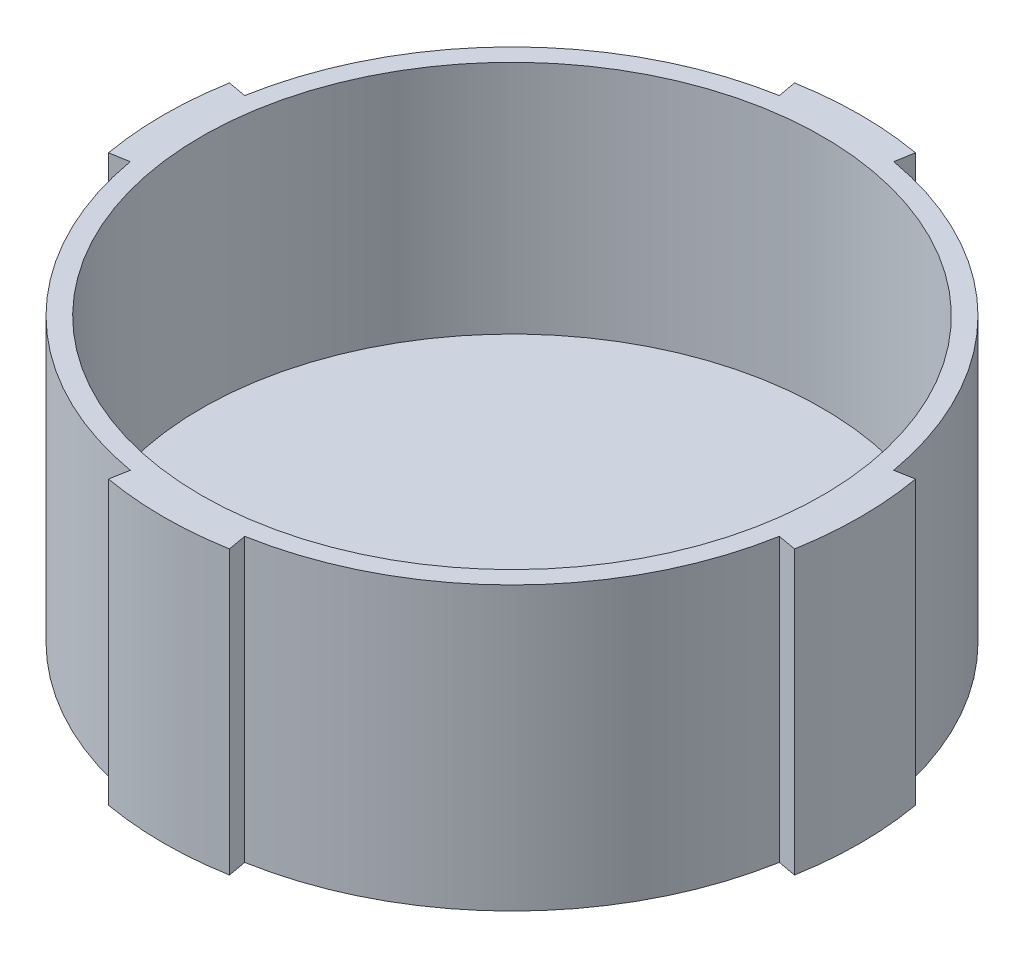
from build123d import *

# Parameters (mm, degrees)
SKETCH1_R           = 37
BOSS_EXTRUDE1_DEPTH = 30
CUT_EXTRUDE1_DEPTH  = 30
SKETCH3_R           = 33
CUT_EXTRUDE2_DEPTH  = 25


with BuildPart() as part:
    # Sketch1 → Boss-Extrude1 (new body)
    with BuildSketch(Plane(origin=(0, 0, 0), x_dir=(1, 0, 0), z_dir=(0, 1, 0))):
        Circle(SKETCH1_R)
    extrude(amount=BOSS_EXTRUDE1_DEPTH)

    # Sketch2 → Cut-Extrude1 (cut)
    with BuildSketch(Plane(origin=(0, 30, 0), x_dir=(1, 0, 0), z_dir=(0, 1, 0))):
        with BuildLine():
            Line((6.424982574, 36.437886861), (6.077686218, 34.468271355))
            ThreePointArc((6.077686218, 34.468271355), (24.748737342, 24.748737342), (34.468271355, 6.077686218))
            Line((34.468271355, 6.077686218), (36.437886861, 6.424982574))
            ThreePointArc((36.437886861, 6.424982574), (26.162950904, 26.162950904), (6.424982574, 36.437886861))
        make_face()
        with BuildLine():
            Line((36.437886861, -6.424982574), (34.468271355, -6.077686218))
            ThreePointArc((34.468271355, -6.077686218), (24.748737342, -24.748737342), (6.077686218, -34.468271355))
            Line((6.077686218, -34.468271355), (6.424982574, -36.437886861))
            ThreePointArc((6.424982574, -36.437886861), (26.162950904, -26.162950904), (36.437886861, -6.424982574))
        make_face()
        with BuildLine():
            Line((-6.424982574, -36.437886861), (-6.077686218, -34.468271355))
            ThreePointArc((-6.077686218, -34.468271355), (-24.748737342, -24.748737342), (-34.468271355, -6.077686218))
            Line((-34.468271355, -6.077686218), (-36.437886861, -6.424982574))
            ThreePointArc((-36.437886861, -6.424982574), (-26.162950904, -26.162950904), (-6.424982574, -36.437886861))
        make_face()
        with BuildLine():
            Line((-36.437886861, 6.424982574), (-34.468271355, 6.077686218))
            ThreePointArc((-34.468271355, 6.077686218), (-24.748737342, 24.748737342), (-6.077686218, 34.468271355))
            Line((-6.077686218, 34.468271355), (-6.424982574, 36.437886861))
            ThreePointArc((-6.424982574, 36.437886861), (-26.162950904, 26.162950904), (-36.437886861, 6.424982574))
        make_face()
    extrude(amount=-CUT_EXTRUDE1_DEPTH, mode=Mode.SUBTRACT)

    # Sketch3 → Cut-Extrude2 (cut)
    with BuildSketch(Plane(origin=(0, 30, 0), x_dir=(1, 0, 0), z_dir=(0, 1, 0))):
        Circle(SKETCH3_R)
    extrude(amount=-CUT_EXTRUDE2_DEPTH, mode=Mode.SUBTRACT)


solid = part.part
